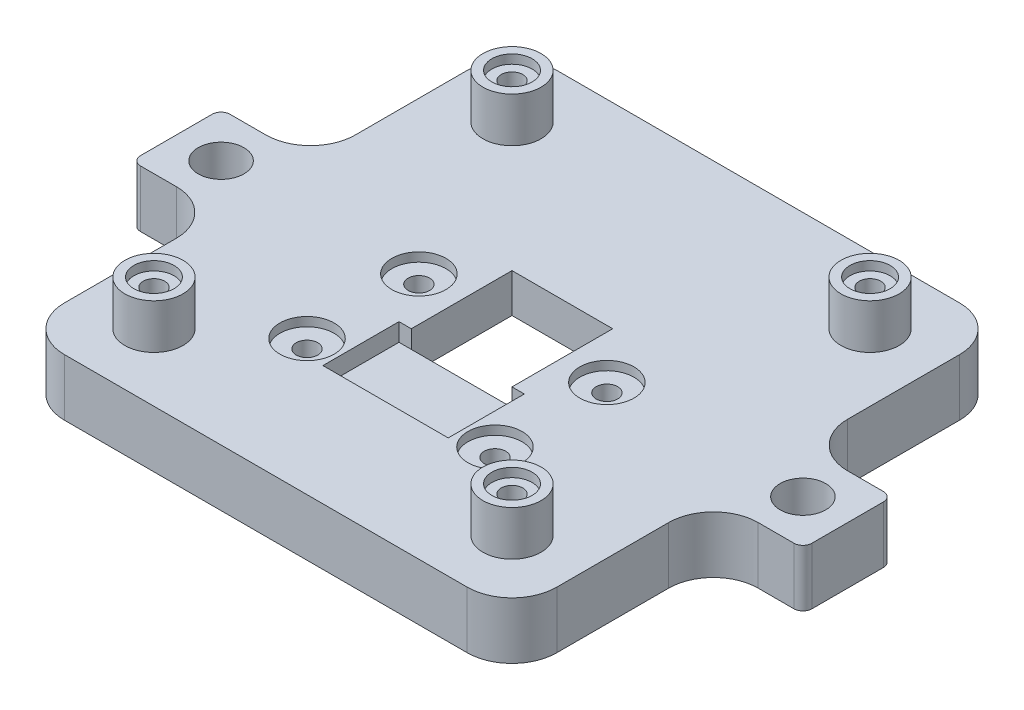
from build123d import *

# Parameters (mm, degrees)
SKETCH1_W                      = 55
SKETCH1_H                      = 55
BOSS_EXTRUDE1_DEPTH            = 6.35
SKETCH2_W                      = 11.25
SKETCH2_H                      = 11.25
CUT_EXTRUDE1_DEPTH             = 7.35
SKETCH3_W                      = 14
SKETCH3_H                      = 8.5
CUT_EXTRUDE2_DEPTH             = 2
CBORE_FOR_M2_SHCS2_D           = 2.4
CBORE_FOR_M2_SHCS2_DEPTH       = 6.35
CBORE_FOR_M2_SHCS2_CBORE_D     = 4.4
CBORE_FOR_M2_SHCS2_CBORE_DEPTH = 2
SKETCH6_R                      = 3.25
BOSS_EXTRUDE2_DEPTH            = 5
CBORE_FOR_M2_SHCS1_D           = 2.4
CBORE_FOR_M2_SHCS1_CBORE_D     = 4.4
CBORE_FOR_M2_SHCS1_CBORE_DEPTH = 2
SKETCH13_R                     = 3.025
CUT_EXTRUDE4_DEPTH             = 1
CHAMFER1_SIZE                  = 2
SKETCH16_W                     = 10
SKETCH16_H                     = 10
BOSS_EXTRUDE3_DEPTH            = 6.35
SKETCH17_R                     = 2.55
CUT_EXTRUDE6_DEPTH             = 12.35
FILLET1_R                      = 5
FILLET2_R                      = 1
SKETCH18_R                     = 2.25
CUT_EXTRUDE7_DEPTH             = 1


with BuildPart() as part:
    # Sketch1 → Boss-Extrude1 (new body)
    with BuildSketch(Plane(origin=(0, 0, 0), x_dir=(1, 0, 0), z_dir=(0, 1, 0))):
        Rectangle(SKETCH1_W, SKETCH1_H)
    extrude(amount=BOSS_EXTRUDE1_DEPTH)

    # Sketch2 → Cut-Extrude1 (cut, through all)
    with BuildSketch(Plane(origin=(0, 6.35, 0), x_dir=(1, 0, 0), z_dir=(0, 1, 0))):
        Rectangle(SKETCH2_W, SKETCH2_H)
    extrude(amount=-CUT_EXTRUDE1_DEPTH, mode=Mode.SUBTRACT)

    # Sketch3 → Cut-Extrude2 (cut)
    with BuildSketch(Plane(origin=(0, 6.35, 0), x_dir=(1, 0, 0), z_dir=(0, 1, 0))):
        with Locations((0, -9.875)):
            Rectangle(SKETCH3_W, SKETCH3_H)
    extrude(amount=-CUT_EXTRUDE2_DEPTH, mode=Mode.SUBTRACT)

    # CBORE for M2 SHCS2
    with Locations(Plane.XZ):
        with Locations((10.5, -0.1), (10.5, 12.4), (-10.5, 12.4), (-10.5, -0.1)):
            CounterBoreHole(CBORE_FOR_M2_SHCS2_D / 2, CBORE_FOR_M2_SHCS2_CBORE_D / 2, CBORE_FOR_M2_SHCS2_CBORE_DEPTH, depth=CBORE_FOR_M2_SHCS2_DEPTH)

    # Sketch6 → Boss-Extrude2 (add)
    with BuildSketch(Plane(origin=(0, 6.35, 0), x_dir=(1, 0, 0), z_dir=(0, 1, 0))):
        with Locations((-20, 20)):
            Circle(SKETCH6_R)
        with Locations((20, 20)):
            Circle(SKETCH6_R)
        with Locations((20, -20)):
            Circle(SKETCH6_R)
        with Locations((-20, -20)):
            Circle(SKETCH6_R)
    extrude(amount=BOSS_EXTRUDE2_DEPTH)

    # CBORE for M2 SHCS1 (through all)
    with Locations(Plane.XZ):
        with Locations((-20, -20), (-20, 20), (20, 20), (20, -20)):
            CounterBoreHole(CBORE_FOR_M2_SHCS1_D / 2, CBORE_FOR_M2_SHCS1_CBORE_D / 2, CBORE_FOR_M2_SHCS1_CBORE_DEPTH)

    # Sketch13 → Cut-Extrude4 (cut)
    with BuildSketch(Plane(origin=(0, 6.35, 0), x_dir=(1, 0, 0), z_dir=(0, 1, 0))):
        with Locations((-10.5, -12.4)):
            Circle(SKETCH13_R)
        with Locations((-10.5, 0.1)):
            Circle(SKETCH13_R)
        with Locations((10.5, -12.4)):
            Circle(SKETCH13_R)
        with Locations((10.5, 0.1)):
            Circle(SKETCH13_R)
    extrude(amount=-CUT_EXTRUDE4_DEPTH, mode=Mode.SUBTRACT)

    # Chamfer1
    chamfer1_edges = [part.edges().sort_by_distance(p)[0] for p in [
        (5.625, 0, 0),
        (0, 0, 5.625),
        (-5.625, 0, 0),
        (0, 0, -5.625),
    ]]
    chamfer(chamfer1_edges, length=CHAMFER1_SIZE)

    # Sketch16 → Boss-Extrude3 (add)
    with BuildSketch(Plane.XZ):
        with Locations((32.5, 0)):
            Rectangle(SKETCH16_W, SKETCH16_H)
        with Locations((-32.5, 0)):
            Rectangle(SKETCH16_W, SKETCH16_H)
    extrude(amount=-BOSS_EXTRUDE3_DEPTH)

    # Sketch17 → Cut-Extrude6 (cut, through all)
    with BuildSketch(Plane.XZ):
        with Locations((32.5, 0)):
            Circle(SKETCH17_R)
        with Locations((-32.5, 0)):
            Circle(SKETCH17_R)
    extrude(amount=-CUT_EXTRUDE6_DEPTH, mode=Mode.SUBTRACT)

    # Fillet1
    fillet1_edges = [part.edges().sort_by_distance(p)[0] for p in [
        (27.5, 3.175, 5),
        (27.5, 3.175, -5),
        (-27.5, 3.175, -5),
        (-27.5, 3.175, 5),
        (27.5, 3.175, 27.5),
        (-27.5, 3.175, 27.5),
        (-27.5, 3.175, -27.5),
        (27.5, 3.175, -27.5),
    ]]
    fillet(fillet1_edges, radius=FILLET1_R)

    # Fillet2
    fillet2_edges = [part.edges().sort_by_distance(p)[0] for p in [
        (37.5, 3.175, -5),
        (37.5, 3.175, 5),
        (-37.5, 3.175, 5),
        (-37.5, 3.175, -5),
    ]]
    fillet(fillet2_edges, radius=FILLET2_R)

    # Sketch18 → Cut-Extrude7 (cut)
    with BuildSketch(Plane(origin=(0, 11.35, 0), x_dir=(1, 0, 0), z_dir=(0, 1, 0))):
        with Locations((-20, 20)):
            Circle(SKETCH18_R)
        with Locations((-20, -20)):
            Circle(SKETCH18_R)
        with Locations((20, 20)):
            Circle(SKETCH18_R)
        with Locations((20, -20)):
            Circle(SKETCH18_R)
    extrude(amount=-CUT_EXTRUDE7_DEPTH, mode=Mode.SUBTRACT)


solid = part.part
